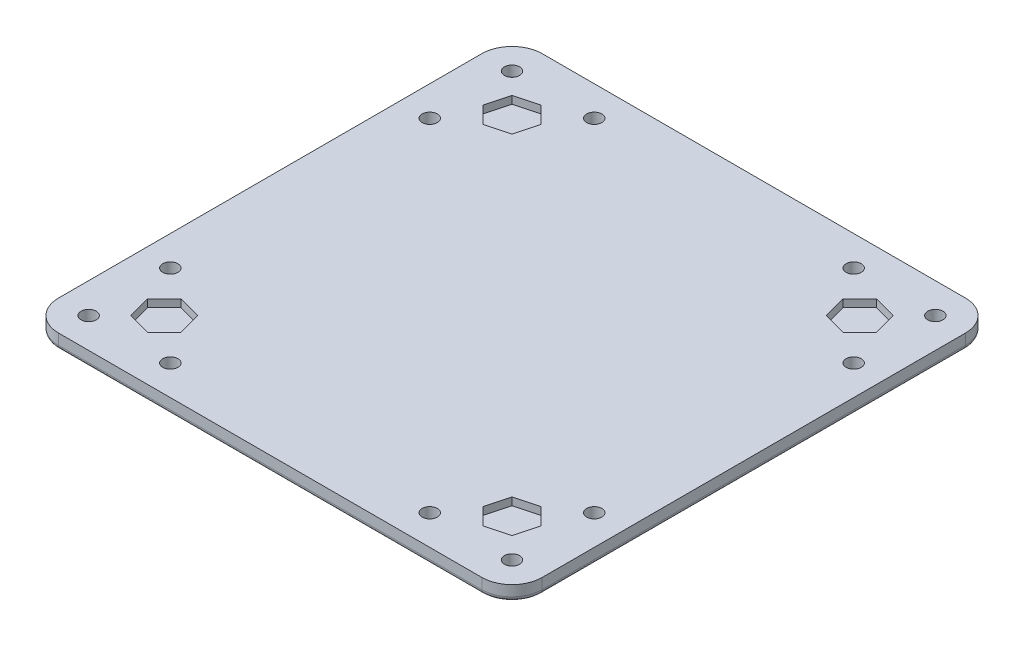
from build123d import *

# Parameters (mm, degrees)
SKETCH1_W           = 203.2
SKETCH1_H           = 203.2
BOSS_EXTRUDE1_DEPTH = 6.35
FILLET1_R           = 12.7
SKETCH2_R           = 3.175
CUT_EXTRUDE1_DEPTH  = 7.35
CUT_EXTRUDE2_DEPTH  = 3.175
FILLET2_R           = 1.905
SKETCH28_R          = 3.175
CUT_EXTRUDE3_DEPTH  = 7.35


with BuildPart() as part:
    # Sketch1 → Boss-Extrude1 (new body)
    with BuildSketch(Plane(origin=(0, 0, 0), x_dir=(1, 0, 0), z_dir=(0, 1, 0))):
        with Locations((101.6, 101.6)):
            Rectangle(SKETCH1_W, SKETCH1_H)
    extrude(amount=BOSS_EXTRUDE1_DEPTH)

    # Fillet1
    fillet1_edges = [part.edges().sort_by_distance(p)[0] for p in [
        (0, 3.175, -203.2),
        (203.2, 3.175, -203.2),
        (203.2, 3.175, 0),
        (0, 3.175, 0),
    ]]
    fillet(fillet1_edges, radius=FILLET1_R)

    # Sketch2 → Cut-Extrude1 (cut, through all)
    with BuildSketch(Plane.XZ):
        with Locations((12.7, -12.7)):
            Circle(SKETCH2_R)
        with Locations((190.5, -12.7)):
            Circle(SKETCH2_R)
        with Locations((190.5, -190.5)):
            Circle(SKETCH2_R)
        with Locations((12.7, -190.5)):
            Circle(SKETCH2_R)
    extrude(amount=-CUT_EXTRUDE1_DEPTH, mode=Mode.SUBTRACT)

    # Sketch22 → Cut-Extrude2 (cut)
    with BuildSketch(Plane(origin=(0, 6.35, 0), x_dir=(1, 0, 0), z_dir=(0, 1, 0))):
        Polygon((181.654219065, 181.654219065), (172.052127253, 184.227091812), (165.022908188, 177.197872747), (167.595780935, 167.595780935), (177.197872747, 165.022908188), (184.227091812, 172.052127253), align=None)
        Polygon((18.972908188, 172.052127253), (21.545780935, 181.654219065), (31.147872747, 184.227091812), (38.177091812, 177.197872747), (35.604219065, 167.595780935), (26.002127253, 165.022908188), align=None)
        Polygon((184.227091812, 31.147872747), (181.654219065, 21.545780935), (172.052127253, 18.972908188), (165.022908188, 26.002127253), (167.595780935, 35.604219065), (177.197872747, 38.177091812), align=None)
        Polygon((21.545780935, 21.545780935), (31.147872747, 18.972908188), (38.177091812, 26.002127253), (35.604219065, 35.604219065), (26.002127253, 38.177091812), (18.972908188, 31.147872747), align=None)
    extrude(amount=-CUT_EXTRUDE2_DEPTH, mode=Mode.SUBTRACT)

    # Fillet2
    fillet2_edges = [part.edges().sort_by_distance(p)[0] for p in [
        (0, 0, -101.6),
        (101.6, 0, -203.2),
        (203.2, 0, -101.6),
        (101.6, 0, 0),
        (199.480256121, 0, -199.480256121),
        (199.480256121, 0, -3.719743879),
        (3.719743879, 0, -3.719743879),
        (3.719743879, 0, -199.480256121),
        (9.525, 0, -190.5),
        (187.325, 0, -190.5),
        (187.325, 0, -12.7),
        (9.525, 0, -12.7),
    ]]
    fillet(fillet2_edges, radius=FILLET2_R)

    # Sketch28 → Cut-Extrude3 (cut, through all)
    with BuildSketch(Plane(origin=(0, 6.35, 0), x_dir=(1, 0, 0), z_dir=(0, 1, 0))):
        with Locations((47.117, 190.627)):
            Circle(SKETCH28_R)
        with Locations((156.083, 190.627)):
            Circle(SKETCH28_R)
        with Locations((190.627, 156.083)):
            Circle(SKETCH28_R)
        with Locations((190.627, 47.117)):
            Circle(SKETCH28_R)
        with Locations((156.083, 12.573)):
            Circle(SKETCH28_R)
        with Locations((47.117, 12.573)):
            Circle(SKETCH28_R)
        with Locations((12.573, 156.083)):
            Circle(SKETCH28_R)
        with Locations((12.573, 47.117)):
            Circle(SKETCH28_R)
    extrude(amount=-CUT_EXTRUDE3_DEPTH, mode=Mode.SUBTRACT)


solid = part.part
